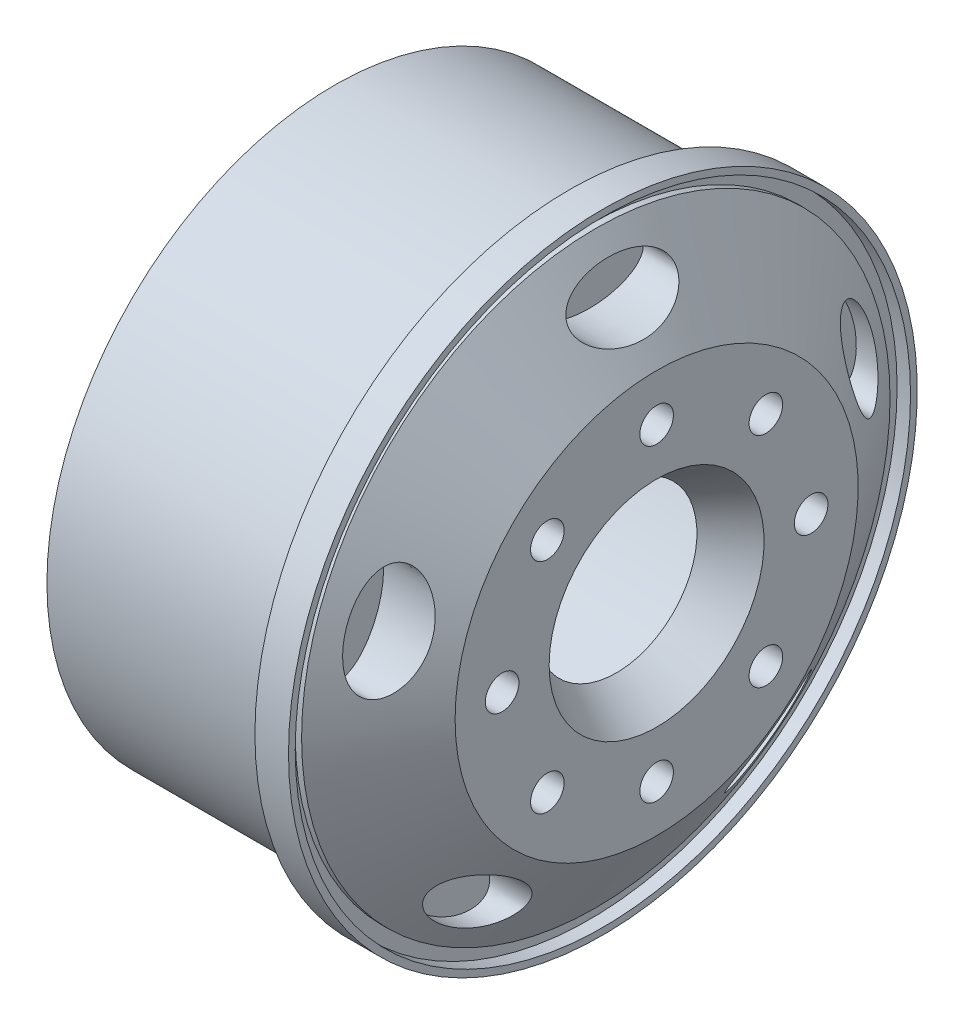
from build123d import *

# Parameters (mm, degrees)
SKETCH4_R          = 1.25
SKETCH4_RX         = 4
SKETCH4_RY         = 2
CUT_EXTRUDE1_DEPTH = 5


with BuildPart() as part:
    # Sketch3 → Revolve1 (revolve)
    with BuildSketch(Plane(origin=(0, 0, 0), x_dir=(1, 0, 0), z_dir=(0, 1, 0))):
        Polygon((10.36932978, 23.4), (8.86932978, 23.4), (8.86932978, 21.4), (-8.61067022, 21.4), (-8.61067022, 18.231946605), (9.211549898, 18.231946605), (12.36932978, 13.417613419), (12.36932978, 6), (15.36932978, 8), (15.36932978, 15), (10.843535586, 21.9), (10.36932978, 21.9), (10.36932978, 22.9), (11.36932978, 22.9), (11.36932978, 23.4), align=None)
    revolve(axis=Axis((-29.774212385, 0, 0), (1, 0, 0)))

    # Sketch4 → Cut-Extrude1 (cut)
    with BuildSketch(Plane(origin=(15.36932978, 0, 0), x_dir=(0, 0, -1), z_dir=(1, 0, 0))):
        with Locations((0, 11.5)):
            Circle(SKETCH4_R)
        with Locations((8.131727984, 8.131727984)):
            Circle(SKETCH4_R)
        with Locations((11.5, 0)):
            Circle(SKETCH4_R)
        with Locations((8.131727984, -8.131727984)):
            Circle(SKETCH4_R)
        with Locations((0, -11.5)):
            Circle(SKETCH4_R)
        with Locations((-8.131727984, -8.131727984)):
            Circle(SKETCH4_R)
        with Locations((-11.5, 0)):
            Circle(SKETCH4_R)
        with Locations((-8.131727984, 8.131727984)):
            Circle(SKETCH4_R)
        with Locations((0, 18.5)):
            Ellipse(SKETCH4_RX, SKETCH4_RY)
        with Locations(Location((17.594545551, 5.716814396), (0, 0, -72))):
            Ellipse(SKETCH4_RX, SKETCH4_RY)
        with Locations(Location((10.874027167, -14.966814396), (0, 0, -144))):
            Ellipse(SKETCH4_RX, SKETCH4_RY)
        with Locations(Location((-10.874027167, -14.966814396), (0, 0, 144))):
            Ellipse(SKETCH4_RX, SKETCH4_RY)
        with Locations(Location((-17.594545551, 5.716814396), (0, 0, 72))):
            Ellipse(SKETCH4_RX, SKETCH4_RY)
    extrude(amount=-CUT_EXTRUDE1_DEPTH, mode=Mode.SUBTRACT)


solid = part.part
